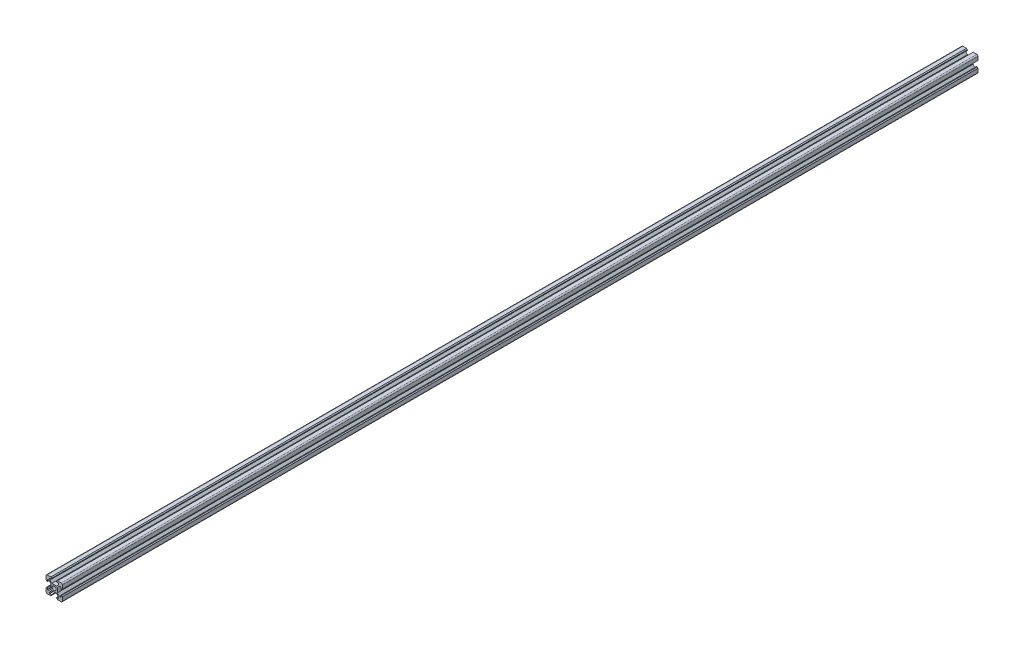
from build123d import *

# Parameters (mm, degrees)
SKETCH1_R           = 2.5
BOSS_EXTRUDE1_DEPTH = 1120


with BuildPart() as part:
    # Sketch1 → Boss-Extrude1 (new body)
    with BuildSketch(Plane.XY):
        with BuildLine():
            Line((2.839339828, 3.9), (-2.839339828, 3.9))
            Line((-2.839339828, 3.9), (-5.5, 6.560660172))
            Line((-5.5, 6.560660172), (-5.5, 8.2))
            Line((-5.5, 8.2), (-3.1, 8.2))
            Line((-3.1, 8.2), (-3.1, 9))
            Line((-3.1, 9), (-4.1, 10))
            Line((-4.1, 10), (-8.5, 10))
            ThreePointArc((-8.5, 10), (-9.560660172, 9.560660172), (-10, 8.5))
            Line((-10, 8.5), (-10, 4.1))
            Line((-10, 4.1), (-9, 3.1))
            Line((-9, 3.1), (-8.2, 3.1))
            Line((-8.2, 3.1), (-8.2, 5.5))
            Line((-8.2, 5.5), (-6.560660172, 5.5))
            Line((-6.560660172, 5.5), (-3.9, 2.839339828))
            Line((-3.9, 2.839339828), (-3.9, -2.839339828))
            Line((-3.9, -2.839339828), (-6.560660172, -5.5))
            Line((-6.560660172, -5.5), (-8.2, -5.5))
            Line((-8.2, -5.5), (-8.2, -3.1))
            Line((-8.2, -3.1), (-9, -3.1))
            Line((-9, -3.1), (-10, -4.1))
            Line((-10, -4.1), (-10, -8.5))
            ThreePointArc((-10, -8.5), (-9.560660172, -9.560660172), (-8.5, -10))
            Line((-8.5, -10), (-4.1, -10))
            Line((-4.1, -10), (-3.1, -9))
            Line((-3.1, -9), (-3.1, -8.2))
            Line((-3.1, -8.2), (-5.5, -8.2))
            Line((-5.5, -8.2), (-5.5, -6.560660172))
            Line((-5.5, -6.560660172), (-2.839339828, -3.9))
            Line((-2.839339828, -3.9), (2.839339828, -3.9))
            Line((2.839339828, -3.9), (5.5, -6.560660172))
            Line((5.5, -6.560660172), (5.5, -8.2))
            Line((5.5, -8.2), (3.1, -8.2))
            Line((3.1, -8.2), (3.1, -9))
            Line((3.1, -9), (4.1, -10))
            Line((4.1, -10), (8.5, -10))
            ThreePointArc((8.5, -10), (9.560660172, -9.560660172), (10, -8.5))
            Line((10, -8.5), (10, -4.1))
            Line((10, -4.1), (9, -3.1))
            Line((9, -3.1), (8.2, -3.1))
            Line((8.2, -3.1), (8.2, -5.5))
            Line((8.2, -5.5), (6.560660172, -5.5))
            Line((6.560660172, -5.5), (3.9, -2.839339828))
            Line((3.9, -2.839339828), (3.9, 2.839339828))
            Line((3.9, 2.839339828), (6.560660172, 5.5))
            Line((6.560660172, 5.5), (8.2, 5.5))
            Line((8.2, 5.5), (8.2, 3.1))
            Line((8.2, 3.1), (9, 3.1))
            Line((9, 3.1), (10, 4.1))
            Line((10, 4.1), (10, 8.5))
            ThreePointArc((10, 8.5), (9.560660172, 9.560660172), (8.5, 10))
            Line((8.5, 10), (4.1, 10))
            Line((4.1, 10), (3.1, 9))
            Line((3.1, 9), (3.1, 8.2))
            Line((3.1, 8.2), (5.5, 8.2))
            Line((5.5, 8.2), (5.5, 6.560660172))
            Line((5.5, 6.560660172), (2.839339828, 3.9))
        make_face()
        Circle(SKETCH1_R, mode=Mode.SUBTRACT)
    extrude(amount=BOSS_EXTRUDE1_DEPTH)


solid = part.part
